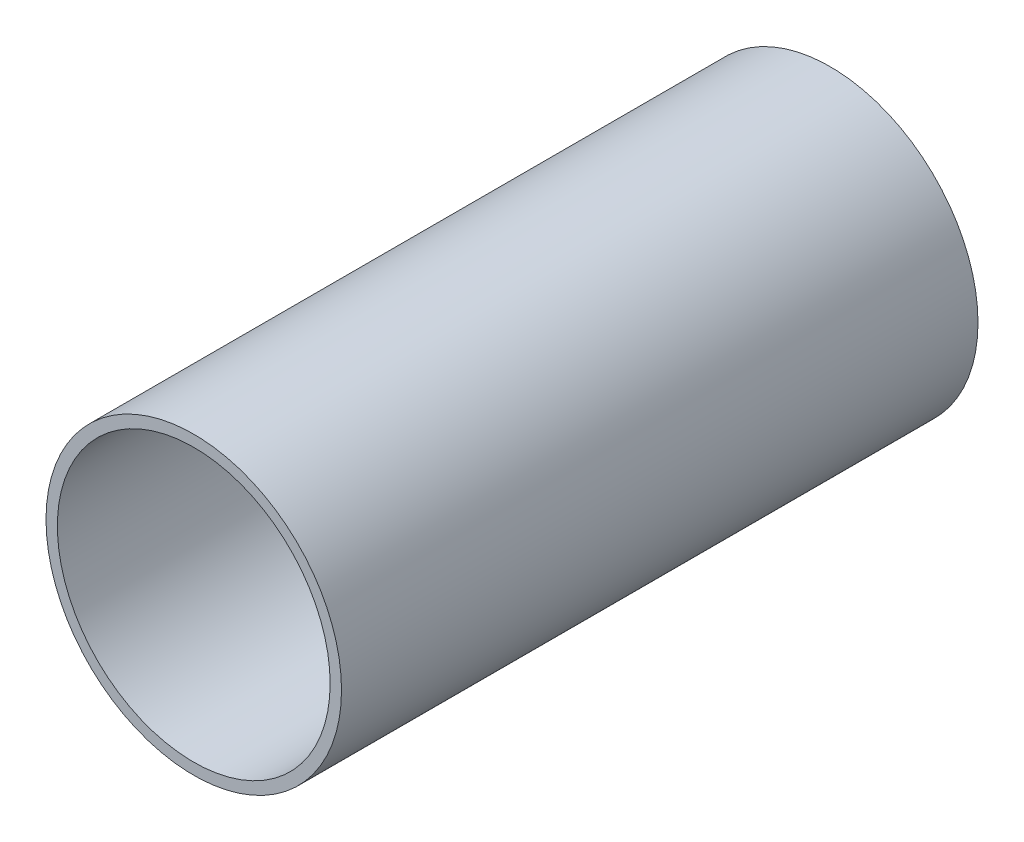
from build123d import *

# Parameters (mm, degrees)
SKETCH1_R           = 41.275
SKETCH1_R_2         = 38.1
BOSS_EXTRUDE1_DEPTH = 177.8


with BuildPart() as part:
    # Sketch1 → Boss-Extrude1 (new body)
    with BuildSketch(Plane.XY):
        Circle(SKETCH1_R)
        Circle(SKETCH1_R_2, mode=Mode.SUBTRACT)
    extrude(amount=BOSS_EXTRUDE1_DEPTH)


solid = part.part
